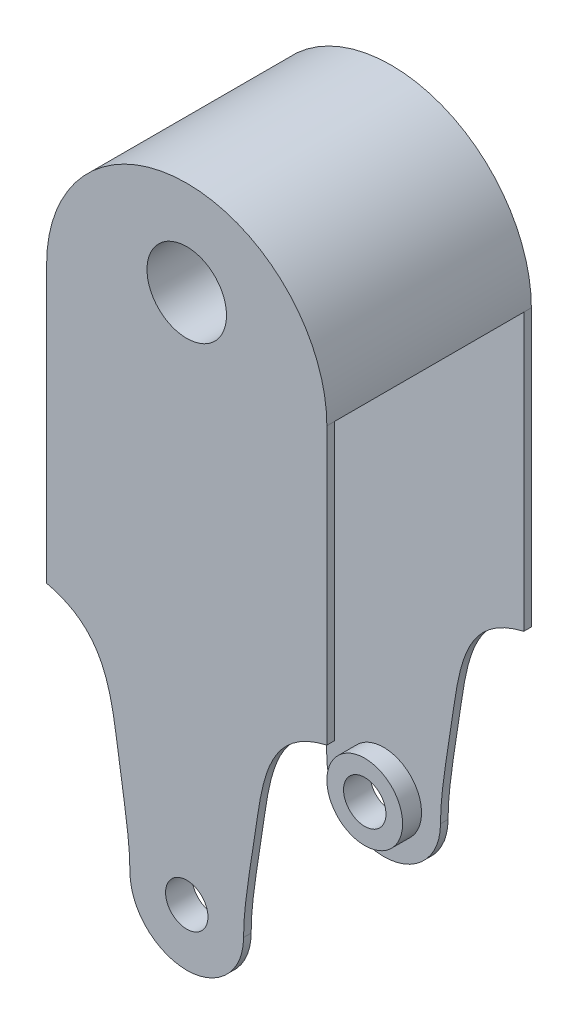
from build123d import *

# Parameters (mm, degrees)
CROQUIS1_R              = 5.6
CROQUIS1_R_2            = 10.5
SALIENTE_EXTRUIR1_DEPTH = 54
CROQUIS6_W              = 54
CROQUIS6_H              = 70
SALIENTE_EXTRUIR3_DEPTH = 74
CORTAR_EXTRUIR13_DEPTH  = 74
CORTAR_EXTRUIR14_DEPTH  = 74
CROQUIS9_W              = 3
CROQUIS9_H              = 11.2
CORTAR_EXTRUIR15_DEPTH  = 74
CROQUIS10_R             = 5.6
CORTAR_EXTRUIR16_DEPTH  = 74
CROQUIS11_R             = 10
CROQUIS11_R_2           = 5.6
SALIENTE_EXTRUIR4_DEPTH = 5
CROQUIS12_R             = 10
CROQUIS12_R_2           = 5.6
SALIENTE_EXTRUIR5_DEPTH = 5
CROQUIS13_W             = 50
CROQUIS13_H             = 73
CORTAR_EXTRUIR17_DEPTH  = 74


with BuildPart() as part:
    # Croquis1 → Saliente-Extruir1 (new body)
    with BuildSketch(Plane.XY):
        with BuildLine():
            Line((0, 143), (0, 70))
            add(Edge.make_bspline(
                [(22, 15), (22, 22.317960933), (17.777719643, 44.524463784), (15.903513438, 66.300635574), (0, 70)],
                knots=[0, 0, 0, 0, 0.399675276, 1, 1, 1, 1], degree=3))
            ThreePointArc((22, 15), (37, 0), (52, 15))
            add(Edge.make_bspline(
                [(52, 15), (52, 22.317960933), (56.222280357, 44.524463784), (58.096486562, 66.300635574), (74, 70)],
                knots=[0, 0, 0, 0, 0.399675276, 1, 1, 1, 1], degree=3))
            Line((74, 70), (74, 143))
            ThreePointArc((74, 143), (37, 180), (0, 143))
        make_face()
        with Locations((37, 15)):
            Circle(CROQUIS1_R, mode=Mode.SUBTRACT)
        with Locations((37, 155)):
            Circle(CROQUIS1_R_2, mode=Mode.SUBTRACT)
    extrude(amount=SALIENTE_EXTRUIR1_DEPTH)

    # Croquis6 → Saliente-Extruir3 (add)
    with BuildSketch(Plane.ZY):
        with Locations((27, 35)):
            Rectangle(CROQUIS6_W, CROQUIS6_H)
    extrude(amount=-SALIENTE_EXTRUIR3_DEPTH)

    # Croquis7 → Cortar-Extruir13 (cut)
    with BuildSketch(Plane(origin=(74, 0, 0), x_dir=(0, 0, -1), z_dir=(1, 0, 0))):
        Polygon((-52, 0), (-2, 0), (-2, 9.4), (-5, 9.4), (-5, 20.6), (-2, 20.6), (-2, 70), (-52, 70), (-52, 20.6), (-49, 20.6), (-49, 9.4), (-52, 9.4), align=None)
    extrude(amount=-CORTAR_EXTRUIR13_DEPTH, mode=Mode.SUBTRACT)

    # Croquis8 → Cortar-Extruir14 (cut)
    with BuildSketch(Plane(origin=(0, 0, 0), x_dir=(-1, 0, 0), z_dir=(0, 0, -1))):
        with BuildLine():
            add(Edge.make_bspline(
                [(-74, 70), (-58.096486562, 66.300635574), (-56.222280357, 44.524463784), (-52, 22.317960933), (-52, 15)],
                knots=[0, 0, 0, 0, 0.600324724, 1, 1, 1, 1], degree=3))
            Line((-74, 70), (-74, 0))
            Line((-74, 0), (-37, 0))
            ThreePointArc((-37, 0), (-47.606601718, 4.393398282), (-52, 15))
        make_face()
        with BuildLine():
            ThreePointArc((-22, 15), (-26.393398282, 4.393398282), (-37, 0))
            Line((-37, 0), (0, 0))
            Line((0, 0), (0, 70))
            add(Edge.make_bspline(
                [(-22, 15), (-22, 22.317960933), (-17.777719643, 44.524463784), (-15.903513438, 66.300635574), (0, 70)],
                knots=[0, 0, 0, 0, 0.399675276, 1, 1, 1, 1], degree=3))
        make_face()
    extrude(amount=-CORTAR_EXTRUIR14_DEPTH, mode=Mode.SUBTRACT)

    # Croquis9 → Cortar-Extruir15 (cut)
    with BuildSketch(Plane(origin=(74, 0, 0), x_dir=(0, 0, -1), z_dir=(1, 0, 0))):
        with Locations((-50.5, 15)):
            Rectangle(CROQUIS9_W, CROQUIS9_H)
        Polygon((-2, 20.6), (-5.198845147, 20.6), (-5, 9.4), (-2, 9.4), align=None)
    extrude(amount=-CORTAR_EXTRUIR15_DEPTH, mode=Mode.SUBTRACT)

    # Croquis10 → Cortar-Extruir16 (cut)
    with BuildSketch(Plane(origin=(0, 0, 0), x_dir=(-1, 0, 0), z_dir=(0, 0, -1))):
        with Locations((-37, 15)):
            Circle(CROQUIS10_R)
    extrude(amount=-CORTAR_EXTRUIR16_DEPTH, mode=Mode.SUBTRACT)

    # Croquis11 → Saliente-Extruir4 (add)
    with BuildSketch(Plane(origin=(0, 0, 52), x_dir=(-1, 0, 0), z_dir=(0, 0, -1))):
        with Locations(Location((-37, 15, 0), (0, 0, 270))):
            Circle(CROQUIS11_R)
        with Locations((-37, 15)):
            Circle(CROQUIS11_R_2, mode=Mode.SUBTRACT)
    extrude(amount=SALIENTE_EXTRUIR4_DEPTH)

    # Croquis12 → Saliente-Extruir5 (add)
    with BuildSketch(Plane.XY.offset(2)):
        with Locations(Location((37, 15, 0), (0, 0, 270))):
            Circle(CROQUIS12_R)
        with Locations(Location((37, 15, 0), (0, 0, 180))):
            Circle(CROQUIS12_R_2, mode=Mode.SUBTRACT)
    extrude(amount=SALIENTE_EXTRUIR5_DEPTH)

    # Croquis13 → Cortar-Extruir17 (cut)
    with BuildSketch(Plane.ZY):
        with Locations((27, 106.5)):
            Rectangle(CROQUIS13_W, CROQUIS13_H)
    extrude(amount=-CORTAR_EXTRUIR17_DEPTH, mode=Mode.SUBTRACT)


solid = part.part
